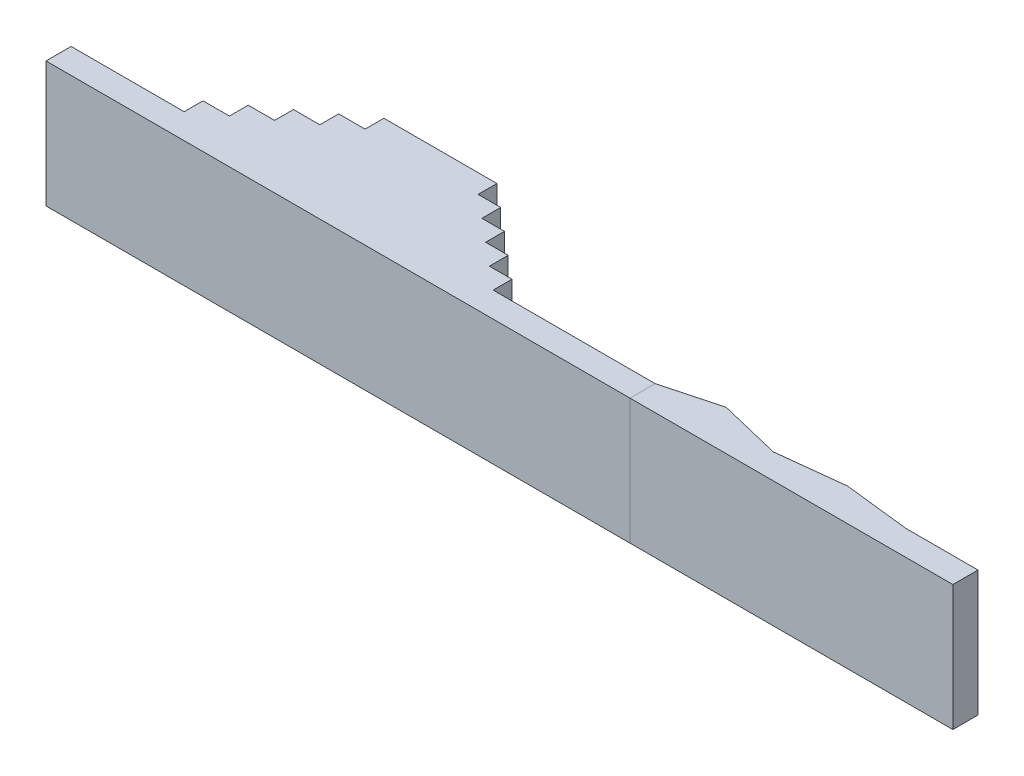
from build123d import *

# Parameters (mm, degrees)
BOSS_EXTRUDE1_DEPTH = 1000
BOSS_EXTRUDE3_DEPTH = 1000


with BuildPart() as part:
    # Sketch1 → Boss-Extrude1 (new body)
    with BuildSketch(Plane(origin=(0, 0, 0), x_dir=(1, 0, 0), z_dir=(0, 1, 0))):
        Polygon((0, 0), (0, 150), (210, 150), (210, 300), (420, 300), (420, 450), (630, 450), (630, 600), (840, 600), (840, 750), (1740, 750), (1740, 600), (1920, 600), (1920, 450), (2100, 450), (2100, 300), (2280, 300), (2280, 150), (2460, 150), (2460, 0), (3750, 0), (3750, -200), (-900, -200), (-900, 0), align=None)
    extrude(amount=BOSS_EXTRUDE1_DEPTH)


with BuildPart() as body_2:
    # Sketch2 → Boss-Extrude3 (new body)
    with BuildSketch(Plane(origin=(0, 1000, 0), x_dir=(1, 0, 0), z_dir=(0, 1, 0))):
        Polygon((3750, -200), (6320, -200), (6320, 0), (5746.179767889, 0), (5223.851175632, 59.776256231), (4688.885601305, 0), (4196.043300547, 119.552512462), (3750, 0), align=None)
    extrude(amount=-BOSS_EXTRUDE3_DEPTH)


solid = Compound([part.part, body_2.part])
